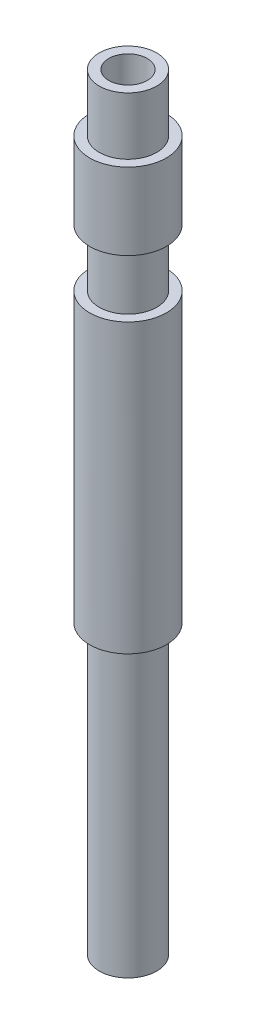
from build123d import *

# Parameters (mm, degrees)
SKETCH_1_R      = 2
SKETCH_1_R_2    = 1
EXTRUDE_1_DEPTH = 40
SKETCH_2_W      = 0.5
SKETCH_2_H      = 3
SKETCH_3_W      = 0.5
SKETCH_3_H      = 15


with BuildPart() as part:
    # Эскиз1 → Бобышка-Вытянуть1 (new body)
    with BuildSketch(Plane(origin=(0, 0, 0), x_dir=(1, 0, 0), z_dir=(0, 1, 0))):
        Circle(SKETCH_1_R)
        Circle(SKETCH_1_R_2, mode=Mode.SUBTRACT)
    extrude(amount=EXTRUDE_1_DEPTH)

    # Эскиз2 → Вырез-Повернуть1 (revolve, cut)
    with BuildSketch(Plane.XY):
        with Locations((1.75, 38.5)):
            Rectangle(SKETCH_2_W, SKETCH_2_H)
        with Locations((1.75, 31.5)):
            Rectangle(SKETCH_2_W, SKETCH_2_H)
    revolve(axis=Axis((0, 40, 0), (0, -1, 0)), mode=Mode.SUBTRACT)

    # Эскиз3 → Вырез-Повернуть2 (revolve, cut)
    with BuildSketch(Plane.XY):
        with Locations((1.75, 7.5)):
            Rectangle(SKETCH_3_W, SKETCH_3_H)
    revolve(axis=Axis((0, 0, 0), (0, 1, 0)), mode=Mode.SUBTRACT)


solid = part.part
